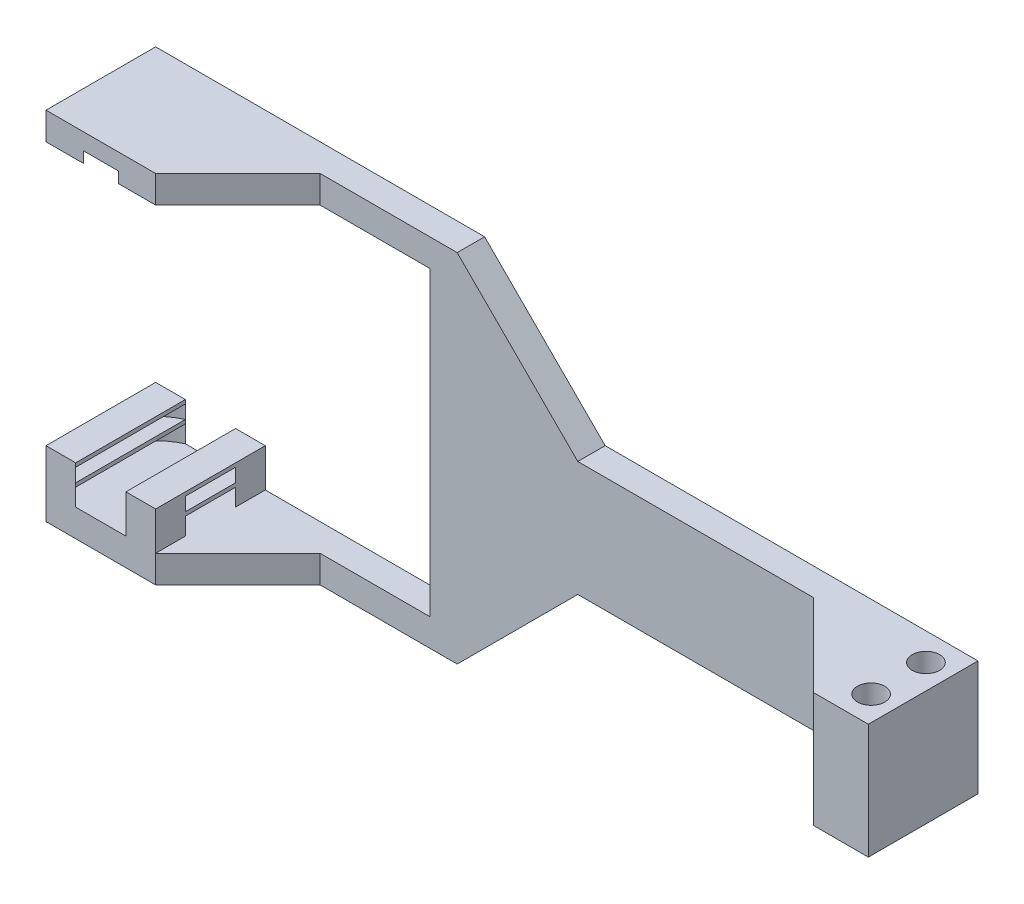
from build123d import *

# Parameters (mm, degrees)
EXTRUSION1_DEPTH        = 20
ESQUISSE3_R             = 2.5
ENL_V_MAT_EXTRU_1_DEPTH = 44
ENL_V_MAT_EXTRU_2_DEPTH = 66
ESQUISSE5_R             = 10.5
ENL_V_MAT_EXTRU_3_DEPTH = 2
EXTRUSION2_DEPTH        = 7
ESQUISSE7_W             = 20
ESQUISSE7_H             = 0.7
EXTRUSION3_DEPTH        = 20
ESQUISSE8_W             = 9.16515139
ESQUISSE8_H             = 7
ENL_V_MAT_EXTRU_4_DEPTH = 21


with BuildPart() as part:
    # Esquisse2 → Extrusion1 (new body)
    with BuildSketch(Plane.XY):
        Polygon((0, 32.5), (0, 27.5), (55, 27.5), (55, -27.5), (0, -27.5), (0, -32.5), (60, -32.5), (82, -10.5), (150, -10.5), (150, 10.5), (82, 10.5), (60, 32.5), align=None)
    extrude(amount=EXTRUSION1_DEPTH)

    # Esquisse3 → Enlèv. mat.-Extru.1 (cut, through all)
    with BuildSketch(Plane.XZ.offset(10.5)):
        with Locations((145.5, 15)):
            Circle(ESQUISSE3_R)
        with Locations((145.5, 5)):
            Circle(ESQUISSE3_R)
    extrude(amount=-ENL_V_MAT_EXTRU_1_DEPTH, mode=Mode.SUBTRACT)

    # Esquisse4 → Enlèv. mat.-Extru.2 (cut, through all)
    with BuildSketch(Plane.XZ.offset(32.5)):
        Polygon((20, 20), (35, 5), (125, 5), (140, 20), align=None)
    extrude(amount=-ENL_V_MAT_EXTRU_2_DEPTH, mode=Mode.SUBTRACT)

    # Esquisse5 → Enlèv. mat.-Extru.3 (cut)
    with BuildSketch(Plane.XZ.offset(-27.5)):
        with Locations((10, 10)):
            Circle(ESQUISSE5_R)
    extrude(amount=-ENL_V_MAT_EXTRU_3_DEPTH, mode=Mode.SUBTRACT)

    # Esquisse6 → Extrusion2 (add)
    with BuildSketch(Plane(origin=(0, -27.5, 0), x_dir=(1, 0, 0), z_dir=(0, 1, 0))):
        with BuildLine():
            Line((14.582575695, 0), (20, 0))
            Line((20, 0), (20, -5.417424305))
            ThreePointArc((20, -5.417424305), (17.778174593, -2.221825407), (14.582575695, 0))
        make_face()
        with BuildLine():
            Line((0, 0), (5.417424305, 0))
            ThreePointArc((5.417424305, 0), (2.221825407, -2.221825407), (0, -5.417424305))
            Line((0, -5.417424305), (0, 0))
        make_face()
        with BuildLine():
            Line((0, -20), (5.417424305, -20))
            ThreePointArc((5.417424305, -20), (2.221825407, -17.778174593), (0, -14.582575695))
            Line((0, -14.582575695), (0, -20))
        make_face()
        with BuildLine():
            Line((20, -14.582575695), (20, -20))
            Line((20, -20), (14.582575695, -20))
            ThreePointArc((14.582575695, -20), (17.778174593, -17.778174593), (20, -14.582575695))
        make_face()
    extrude(amount=EXTRUSION2_DEPTH)

    # Esquisse7 → Extrusion3 (add)
    with BuildSketch(Plane.ZY):
        with Locations((10, -20.85)):
            Rectangle(ESQUISSE7_W, ESQUISSE7_H)
        with Locations((10, -24)):
            Rectangle(ESQUISSE7_W, ESQUISSE7_H)
    extrude(amount=-EXTRUSION3_DEPTH)

    # Esquisse8 → Enlèv. mat.-Extru.4 (cut, through all)
    with BuildSketch(Plane.XY.offset(20)):
        with Locations((10, -24)):
            Rectangle(ESQUISSE8_W, ESQUISSE8_H)
    extrude(amount=-ENL_V_MAT_EXTRU_4_DEPTH, mode=Mode.SUBTRACT)


solid = part.part
